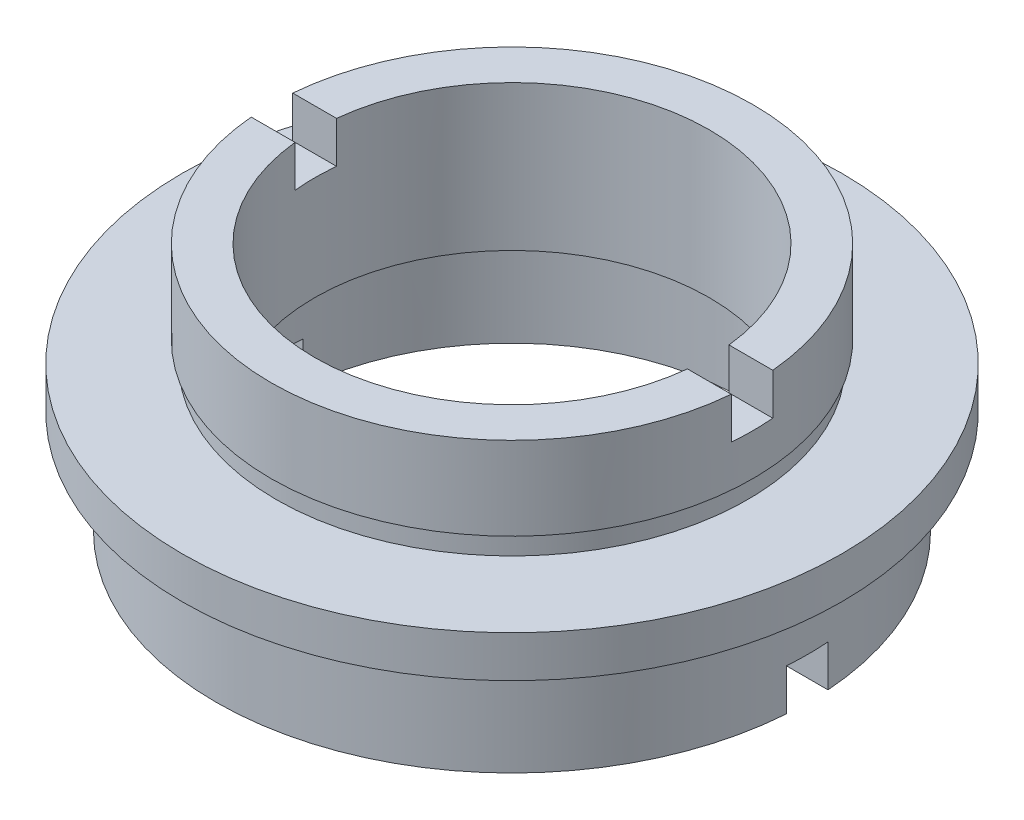
from build123d import *

# Parameters (mm, degrees)
SKETCH_2_W          = 2
SKETCH_2_H          = 3.593987872
SKETCH_2_H_2        = 6.667892238
CUT_EXTRUDE_1_DEPTH = 39.5


with BuildPart() as part:
    # 草图1 → 旋转1 (revolve)
    with BuildSketch(Plane.XY, mode=Mode.PRIVATE) as revolve_1_sk:
        Polygon((-9.5, 12), (-11.6, 12), (-11.6, 8), (-11.35, 8), (-11.35, 7), (-15.875, 7), (-15.875, 5), (-13.75, 5), (-13.75, 4), (-14.25, 4), (-14.25, 0), (-11.1, 0), (-11.1, 4), (-11.7, 4), (-11.7, 5), (-9.5, 5), align=None)
    revolve(revolve_1_sk.sketch.rotate(Axis((0, 22.677499451, 0), (0, -1, 0)), 270), axis=Axis((0, 22.677499451, 0), (0, -1, 0)))  # turned: the seam where the file's is

    # 草图2 → 切除-拉伸1 (cut, symmetric)
    with BuildSketch(Plane(origin=(0, 0, 0), x_dir=(0, 0, -1), z_dir=(1, 0, 0))):
        with Locations((0, 11.796993936)):
            Rectangle(SKETCH_2_W, SKETCH_2_H)
        with Locations((0, -1.333946119)):
            Rectangle(SKETCH_2_W, SKETCH_2_H_2)
    extrude(amount=CUT_EXTRUDE_1_DEPTH, both=True, mode=Mode.SUBTRACT)


solid = part.part
